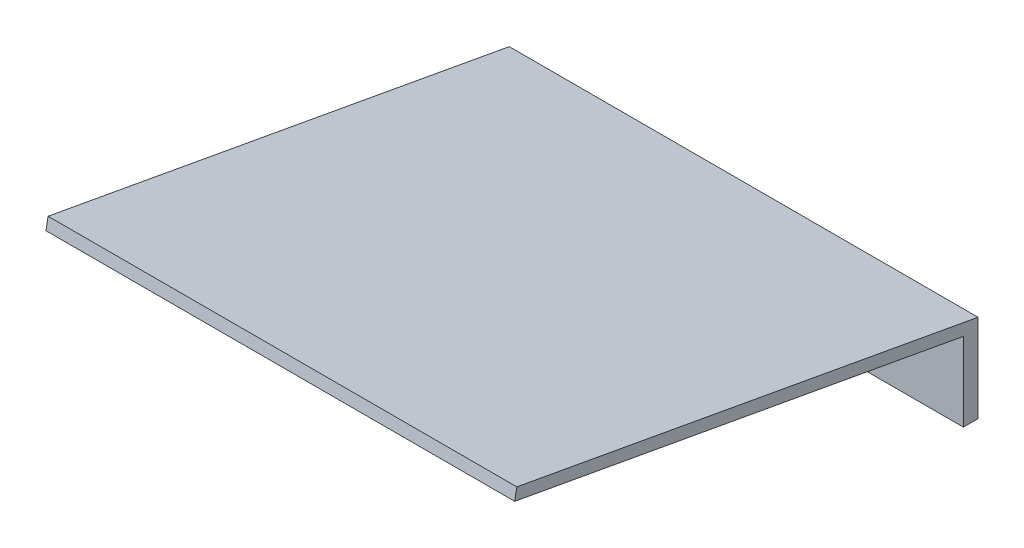
from build123d import *

# Parameters (mm, degrees)
RESSALTO_EXTRUS_O1_DEPTH = 40


with BuildPart() as part:
    # Esboço1 → Ressalto-extrusão1 (new body, symmetric)
    with BuildSketch(Plane(origin=(80, 0, 0), x_dir=(0, 0, -1), z_dir=(1, 0, 0))):
        Polygon((-2.5, 0), (0, 0), (0, 15), (-78.714253951, 29.285175007), (-79.071383326, 27.317318658), (-2.5, 13.421034867), align=None)
    extrude(amount=RESSALTO_EXTRUS_O1_DEPTH, both=True)


solid = part.part
